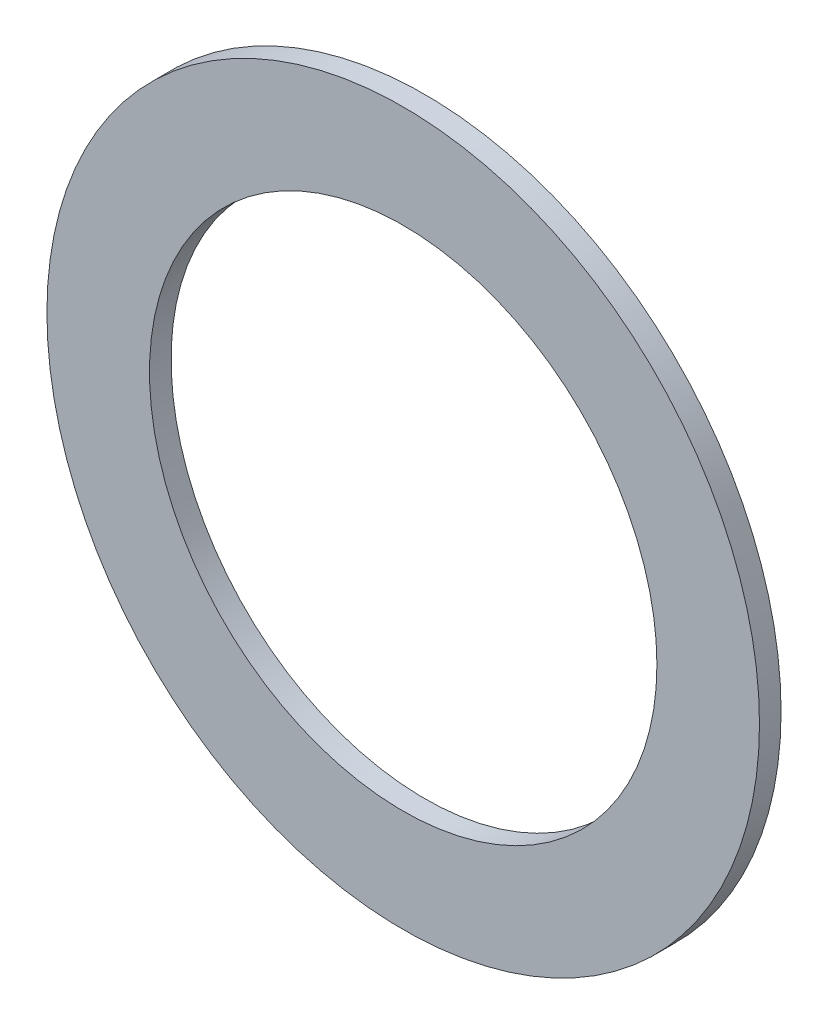
from build123d import *

# Parameters (mm, degrees)
SKETCH1_R          = 8.382
SKETCH1_R_2        = 5.969
BASE_EXTRUDE_DEPTH = 0.508


with BuildPart() as part:
    # Sketch1 → Base-Extrude (new body)
    with BuildSketch(Plane.XY):
        Circle(SKETCH1_R)
        Circle(SKETCH1_R_2, mode=Mode.SUBTRACT)
    extrude(amount=BASE_EXTRUDE_DEPTH)


solid = part.part
